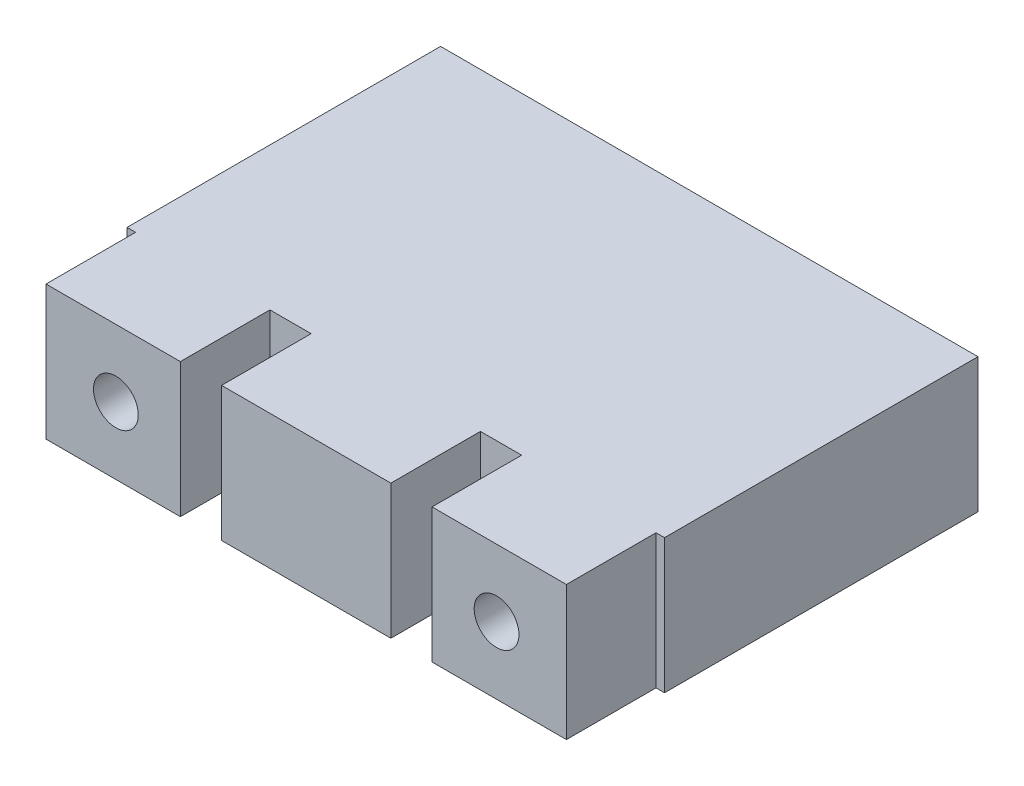
from build123d import *

# Parameters (mm, degrees)
SKETCH1_W           = 12.0015
SKETCH1_H           = 9.525
BOSS_EXTRUDE3_DEPTH = 6.35
SKETCH4_W           = 38.1
SKETCH4_H           = 9.525
BOSS_EXTRUDE4_DEPTH = 22.225
SKETCH2_W           = 9.525
SKETCH2_H           = 9.525
SKETCH2_R           = 1.5875
BOSS_EXTRUDE5_DEPTH = 6.35


with BuildPart() as part:
    # Sketch1 → Boss-Extrude3 (new body)
    with BuildSketch(Plane.XY):
        with Locations((6.00075, 4.7625)):
            Rectangle(SKETCH1_W, SKETCH1_H)
    extrude(amount=-BOSS_EXTRUDE3_DEPTH)

    # Sketch4 → Boss-Extrude4 (add)
    with BuildSketch(Plane(origin=(0, 0, -6.35), x_dir=(-1, 0, 0), z_dir=(0, 0, -1))):
        with Locations((-6.00075, 4.7625)):
            Rectangle(SKETCH4_W, SKETCH4_H)
    extrude(amount=BOSS_EXTRUDE4_DEPTH)

    # Sketch2 → Boss-Extrude5 (add)
    with BuildSketch(Plane.XY):
        with Locations((-7.6835, 4.7625)):
            Rectangle(SKETCH2_W, SKETCH2_H)
        with Locations((-7.493, 4.7625)):
            Circle(SKETCH2_R, mode=Mode.SUBTRACT)
    boss_extrude5 = extrude(amount=-BOSS_EXTRUDE5_DEPTH)

    # Mirror8: Boss-Extrude5 across plane
    add(boss_extrude5.mirror(Plane(origin=(6.00075, 0, 0), x_dir=(0, 0, 1), z_dir=(1, 0, 0))))


solid = part.part
